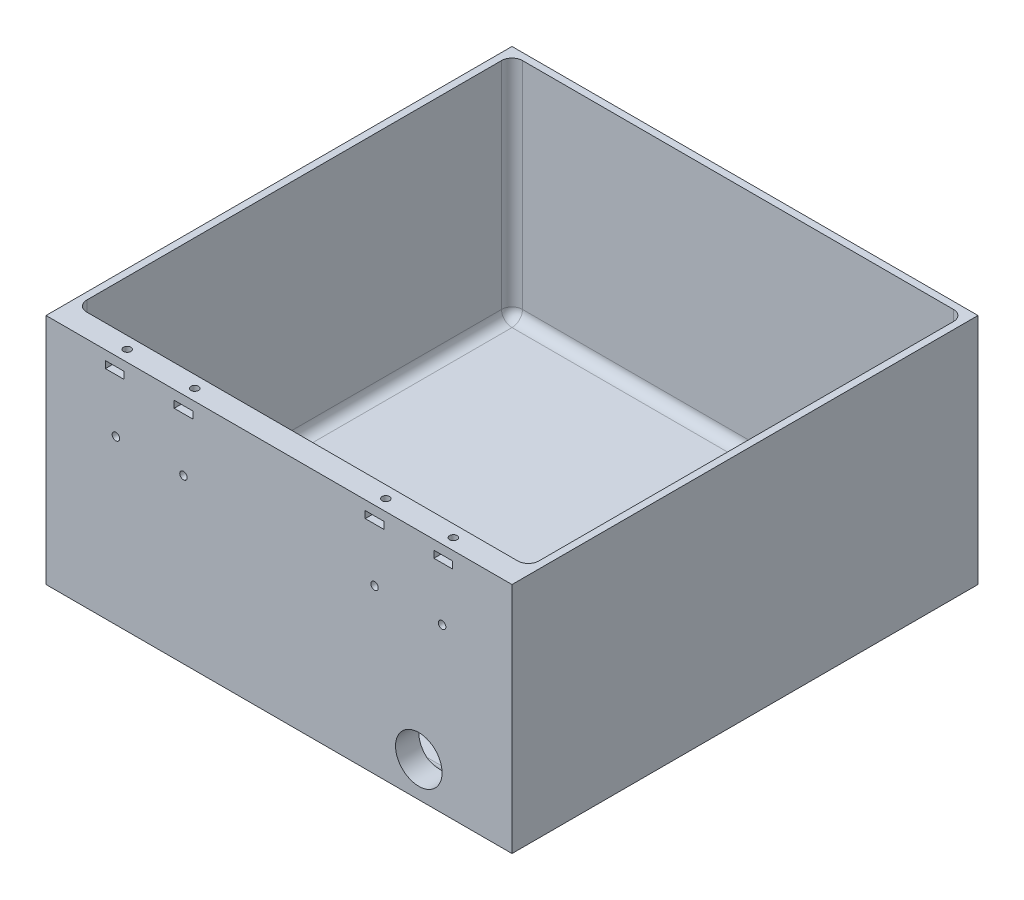
from build123d import *

# Parameters (mm, degrees)
CROQUIS1_W              = 200
CROQUIS1_H              = 200
SALIENTE_EXTRUIR1_DEPTH = 100
CROQUIS2_W              = 194
CROQUIS2_H              = 187
CORTAR_EXTRUIR1_DEPTH   = 97
REDONDEO2_R             = 4.5
CROQUIS3_R              = 1.6
CROQUIS3_W              = 8
CROQUIS3_H              = 3
CORTAR_EXTRUIR2_DEPTH   = 10
CORTAR_EXTRUIR3_REACH   = 202
CROQUIS4_R              = 10
CROQUIS5_R              = 1.6
CORTAR_EXTRUIR4_DEPTH   = 4


with BuildPart() as part:
    # Croquis1 → Saliente-Extruir1 (new body)
    with BuildSketch(Plane(origin=(0, 0, 0), x_dir=(1, 0, 0), z_dir=(0, 1, 0))):
        Rectangle(CROQUIS1_W, CROQUIS1_H)
    extrude(amount=SALIENTE_EXTRUIR1_DEPTH)

    # Croquis2 → Cortar-Extruir1 (cut)
    with BuildSketch(Plane(origin=(0, 100, 0), x_dir=(1, 0, 0), z_dir=(0, 1, 0))):
        with Locations((0, 3.5)):
            Rectangle(CROQUIS2_W, CROQUIS2_H)
    extrude(amount=-CORTAR_EXTRUIR1_DEPTH, mode=Mode.SUBTRACT)

    # Redondeo2
    redondeo2_edges = [part.edges().sort_by_distance(p)[0] for p in [
        (-97, 51.5, 90),
        (-97, 51.5, -97),
        (97, 51.5, -97),
        (97, 51.5, 90),
        (-97, 3, -3.5),
        (0, 3, -97),
        (97, 3, -3.5),
        (0, 3, 90),
    ]]
    fillet(redondeo2_edges, radius=REDONDEO2_R)

    # Croquis3 → Cortar-Extruir2 (cut)
    with BuildSketch(Plane.XY.offset(100)):
        with Locations((-70, 70)):
            Circle(CROQUIS3_R)
        with Locations((-41, 70)):
            Circle(CROQUIS3_R)
        with Locations((-70.5, 94.5)):
            Rectangle(CROQUIS3_W, CROQUIS3_H)
        with Locations((-41, 94.5)):
            Rectangle(CROQUIS3_W, CROQUIS3_H)
    cortar_extruir2 = extrude(amount=-CORTAR_EXTRUIR2_DEPTH, mode=Mode.SUBTRACT)

    # Simetría1: Cortar-Extruir2 across plane
    add(cortar_extruir2.mirror(Plane(origin=(0, 0, 0), x_dir=(0, 0, 1), z_dir=(1, 0, 0))), mode=Mode.SUBTRACT)

    # Croquis4 → Cortar-Extruir3 (cut, up to next)
    with BuildSketch(Plane.XY.offset(100), mode=Mode.PRIVATE) as cortar_extruir3_sk1:
        with Locations((60, 15)):
            Circle(CROQUIS4_R)
    cortar_extruir3_tool1 = extrude(cortar_extruir3_sk1.sketch, amount=-CORTAR_EXTRUIR3_REACH, mode=Mode.PRIVATE) & part.part
    add(cortar_extruir3_tool1.solids().sort_by_distance((60, 15, 100))[0], mode=Mode.SUBTRACT)

    # Croquis5 → Cortar-Extruir4 (cut)
    with BuildSketch(Plane(origin=(0, 100, 0), x_dir=(1, 0, 0), z_dir=(0, 1, 0))):
        with Locations((-70, -95.159266914)):
            Circle(CROQUIS5_R)
        with Locations((-41, -95.159266914)):
            Circle(CROQUIS5_R)
    cortar_extruir4 = extrude(amount=-CORTAR_EXTRUIR4_DEPTH, mode=Mode.SUBTRACT)

    # Simetría2: Cortar-Extruir4 across plane
    add(cortar_extruir4.mirror(Plane(origin=(0, 0, 0), x_dir=(0, 0, 1), z_dir=(1, 0, 0))), mode=Mode.SUBTRACT)


solid = part.part
